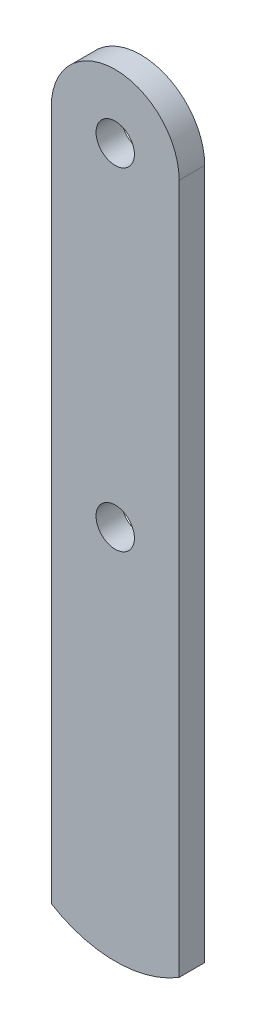
from build123d import *

# Parameters (mm, degrees)
SKETCH1_R           = 1.5
BOSS_EXTRUDE1_DEPTH = 2


with BuildPart() as part:
    # Sketch1 → Boss-Extrude1 (new body)
    with BuildSketch(Plane.XY):
        with BuildLine():
            Line((-5, 24.5), (-5, -29.5))
            ThreePointArc((-5, -29.5), (0, -30.913706536), (5, -29.5))
            Line((5, -29.5), (5, 24.5))
            ThreePointArc((5, 24.5), (0, 29.5), (-5, 24.5))
        make_face()
        with Locations((0, 24.5)):
            Circle(SKETCH1_R, mode=Mode.SUBTRACT)
        with Locations((0, -1.5)):
            Circle(SKETCH1_R, mode=Mode.SUBTRACT)
    extrude(amount=BOSS_EXTRUDE1_DEPTH)


solid = part.part
